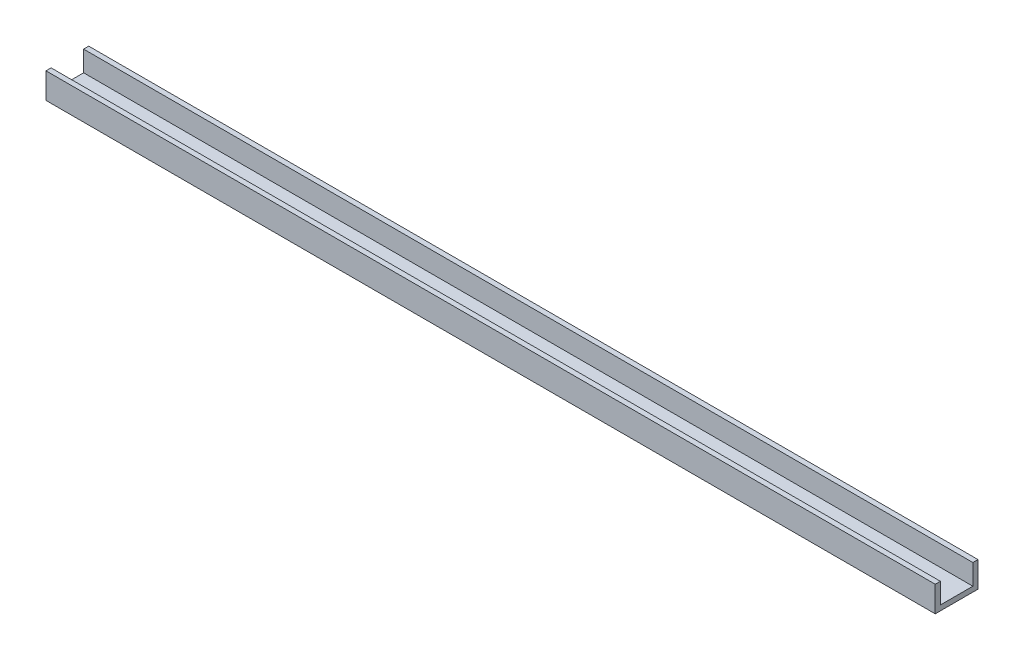
from build123d import *

# Parameters (mm, degrees)
EXTRUDE_1_DEPTH = 520


with BuildPart() as part:
    # Эскиз1 → Вытянуть-Тонкостенный1 (new body)
    with BuildSketch(Plane(origin=(0, 0, 0), x_dir=(0, 0, -1), z_dir=(1, 0, 0))):
        Polygon((-12.5, 15), (-12.5, 0), (12.5, 0), (12.5, 15), (9.5, 15), (9.5, 3), (-9.5, 3), (-9.5, 15), align=None)
    extrude(amount=EXTRUDE_1_DEPTH)


solid = part.part
